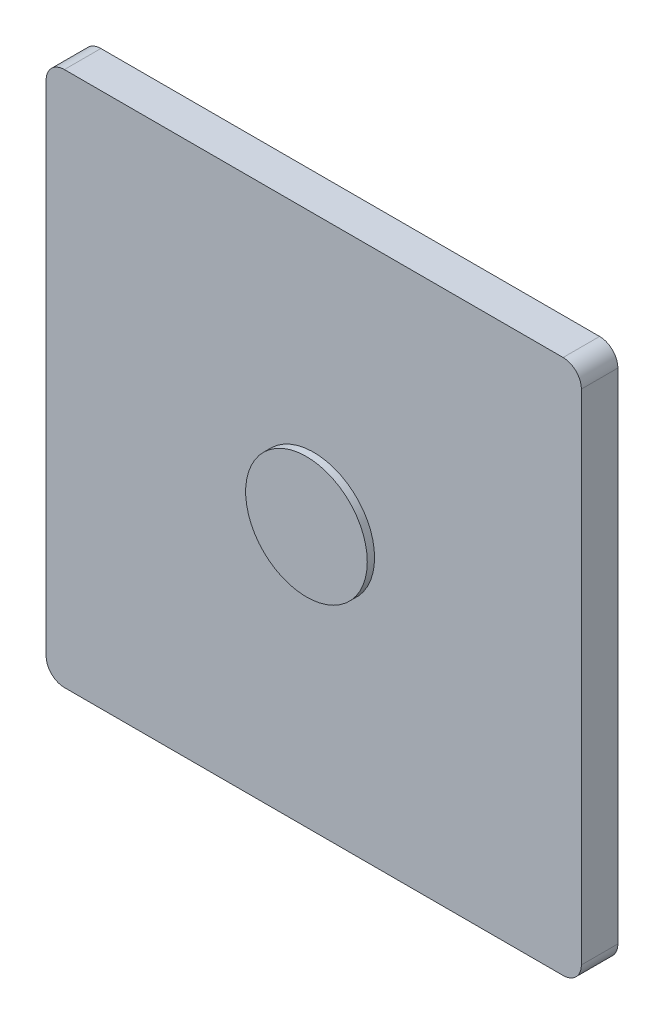
from build123d import *

# Parameters (mm, degrees)
RESSALTO_EXTRUS_O1_DEPTH = 3
ESBO_O5_R                = 5
RESSALTO_EXTRUS_O2_DEPTH = 0.6


with BuildPart() as part:
    # Esboço4 → Ressalto-extrusão1 (new body)
    with BuildSketch(Plane.XY):
        with BuildLine():
            Line((-22, 0), (-22, 20.5))
            ThreePointArc((-22, 20.5), (-21.560660172, 21.560660173), (-20.499999999, 22.000000002))
            Line((-20.499999999, 22.000000002), (1e-09, 22.000000002))
            Line((1e-09, 22.000000002), (20.500000001, 22.000000002))
            ThreePointArc((20.500000001, 22.000000002), (21.560660174, 21.560660173), (22.000000003, 20.5))
            Line((22.000000003, 20.5), (22.000000003, 0))
            Line((22.000000003, 0), (22.000000003, -20.5))
            ThreePointArc((22.000000003, -20.5), (21.560660175, -21.560660173), (20.500000002, -22.000000002))
            Line((20.500000002, -22.000000002), (1e-09, -22.000000002))
            Line((1e-09, -22.000000002), (-20.499999999, -22.000000002))
            ThreePointArc((-20.499999999, -22.000000002), (-21.560660172, -21.560660173), (-22, -20.5))
            Line((-22, -20.5), (-22, 0))
        make_face()
    extrude(amount=RESSALTO_EXTRUS_O1_DEPTH)

    # Esboço5 → Ressalto-extrusão2 (add)
    with BuildSketch(Plane.XY.offset(3)):
        Circle(ESBO_O5_R)
    extrude(amount=RESSALTO_EXTRUS_O2_DEPTH)


solid = part.part
